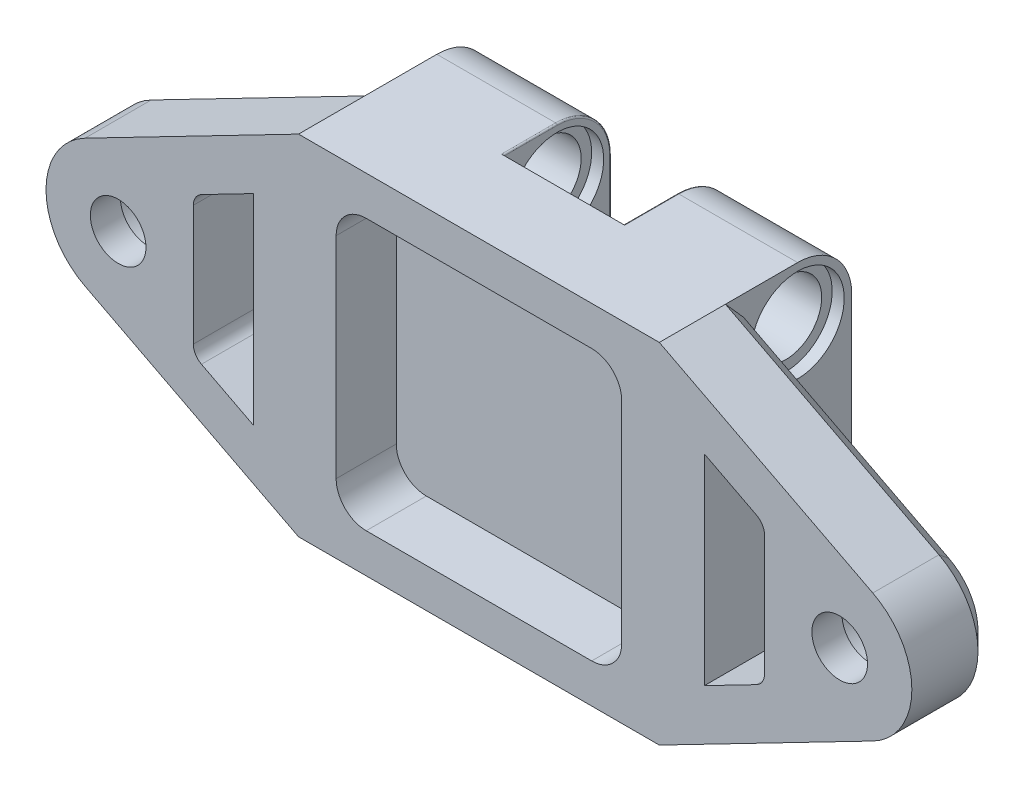
from build123d import *

# Parameters (mm, degrees)
SKETCH_2_R                 = 1.85
EXTRUDE_1_DEPTH            = 5.6
SKETCH_3_R                 = 2.95
CUT_EXTRUDE_1_DEPTH        = 3.6
SKETCH_4_W                 = 8
SKETCH_4_H                 = 23.2
EXTRUDE_2_DEPTH            = 7.2
SKETCH_5_R                 = 2.4
CUT_EXTRUDE_2_DEPTH        = 29.8
CUT_EXTRUDE_2_DEPTH_BACK   = 29.8
FILLET_1_R                 = 3.6
SKETCH_6_R                 = 3.1
CUT_EXTRUDE_3_DEPTH        = 0.8
MIRROR_2_COPY_1_SKETCH_R   = 3.1
MIRROR_2_COPY_1_DEPTH      = 0.8
CUT_EXTRUDE_4_DEPTH        = 6.6
SKETCH_8_W                 = 19
SKETCH_8_H                 = 18
CUT_EXTRUDE_5_DEPTH        = 4
FILLET_3_R                 = 2
FILLET_4_R                 = 0.1
FILLET_5_R                 = 1
CHAMFER_1_SIZE             = 1
FILLET_5_OF_MIRROR_3_R     = 1
CHAMFER_1_OF_MIRROR_3_SIZE = 1
CHAMFER_2_SIZE             = 1.2
SKETCH_9_W                 = 0.1
SKETCH_9_H                 = 1.6
EXTRUDE_3_DEPTH            = 8


with BuildPart() as part:
    # ｽｹｯﾁ2 → ﾎﾞｽ - 押し出し1 (new body)
    with BuildSketch(Plane.XY):
        with BuildLine():
            Line((-12, 11.6), (-26.202629265, 4.264788895))
            ThreePointArc((-26.202629265, 4.264788895), (-28.8, 0), (-26.202629265, -4.264788895))
            Line((-26.202629265, -4.264788895), (-12, -11.6))
            Line((-12, -11.6), (12, -11.6))
            Line((12, -11.6), (26.202629265, -4.264788895))
            ThreePointArc((26.202629265, -4.264788895), (28.8, 0), (26.202629265, 4.264788895))
            Line((26.202629265, 4.264788895), (12, 11.6))
            Line((12, 11.6), (-12, 11.6))
        make_face()
        with Locations((-24, 0)):
            Circle(SKETCH_2_R, mode=Mode.SUBTRACT)
        with Locations((24, 0)):
            Circle(SKETCH_2_R, mode=Mode.SUBTRACT)
    extrude(amount=EXTRUDE_1_DEPTH)

    # ｽｹｯﾁ3 → ｶｯﾄ - 押し出し1 (cut)
    with BuildSketch(Plane(origin=(0, 0, 0), x_dir=(-1, 0, 0), z_dir=(0, 0, -1))):
        with Locations((-24, 0)):
            Circle(SKETCH_3_R)
        with Locations((24, 0)):
            Circle(SKETCH_3_R)
    extrude(amount=-CUT_EXTRUDE_1_DEPTH, mode=Mode.SUBTRACT)

    # ｽｹｯﾁ4 → ﾎﾞｽ - 押し出し2 (add)
    with BuildSketch(Plane(origin=(0, 0, 0), x_dir=(-1, 0, 0), z_dir=(0, 0, -1))):
        with Locations((-8, 0)):
            Rectangle(SKETCH_4_W, SKETCH_4_H)
        with Locations((8, 0)):
            Rectangle(SKETCH_4_W, SKETCH_4_H)
    extrude(amount=EXTRUDE_2_DEPTH)

    # ｽｹｯﾁ5 → ｶｯﾄ - 押し出し2 (cut, two sides)
    with BuildSketch(Plane(origin=(0, 0, 0), x_dir=(0, 0, -1), z_dir=(1, 0, 0))) as cut_extrude_2_sk:
        with Locations((3.6, 8)):
            Circle(SKETCH_5_R)
        with Locations((3.6, -8)):
            Circle(SKETCH_5_R)
        with BuildLine():
            Line((2.8, 2.2627417), (2.8, 0.8))
            Line((2.8, 0.8), (1.3372583, 0.8))
            ThreePointArc((1.3372583, 0.8), (1.2, 0), (1.3372583, -0.8))
            Line((1.3372583, -0.8), (2.8, -0.8))
            Line((2.8, -0.8), (2.8, -2.2627417))
            ThreePointArc((2.8, -2.2627417), (3.6, -2.4), (4.4, -2.2627417))
            Line((4.4, -2.2627417), (4.4, -0.8))
            Line((4.4, -0.8), (5.8627417, -0.8))
            ThreePointArc((5.8627417, -0.8), (6, 0), (5.8627417, 0.8))
            Line((5.8627417, 0.8), (4.4, 0.8))
            Line((4.4, 0.8), (4.4, 2.2627417))
            ThreePointArc((4.4, 2.2627417), (3.6, 2.4), (2.8, 2.2627417))
        make_face()
    extrude(amount=CUT_EXTRUDE_2_DEPTH, mode=Mode.SUBTRACT)
    extrude(cut_extrude_2_sk.sketch, amount=-CUT_EXTRUDE_2_DEPTH_BACK, mode=Mode.SUBTRACT)

    # ﾌｨﾚｯﾄ1
    fillet_1_edges = [part.edges().sort_by_distance(p)[0] for p in [
        (8, -11.6, -7.2),
        (8, 11.6, -7.2),
        (-8, -11.6, -7.2),
        (-8, 11.6, -7.2),
    ]]
    fillet(fillet_1_edges, radius=FILLET_1_R)

    # ｽｹｯﾁ6 → ｶｯﾄ - 押し出し3 (cut)
    with BuildSketch(Plane.ZY.offset(-4)):
        with Locations((-3.6, 8)):
            Circle(SKETCH_6_R)
        with Locations((-3.6, -8)):
            Circle(SKETCH_6_R)
    cut_extrude_3 = extrude(amount=-CUT_EXTRUDE_3_DEPTH, mode=Mode.SUBTRACT)

    # ﾐﾗｰ1: ｶｯﾄ - 押し出し3 across plane
    add(cut_extrude_3.mirror(Plane(origin=(8, 0, 0), x_dir=(0, 0, 1), z_dir=(1, 0, 0))), mode=Mode.SUBTRACT)

    # ﾐﾗｰ2: ｶｯﾄ - 押し出し3 across plane
    add(cut_extrude_3.mirror(Plane(origin=(0, 0, 0), x_dir=(0, 0, 1), z_dir=(1, 0, 0))), mode=Mode.SUBTRACT)

    # ﾐﾗｰ2 copy 1 sketch → ﾐﾗｰ2 copy 1 (cut)
    with BuildSketch(Plane.ZY.offset(12)):
        with Locations((-3.6, 8)):
            Circle(MIRROR_2_COPY_1_SKETCH_R)
        with Locations((-3.6, -8)):
            Circle(MIRROR_2_COPY_1_SKETCH_R)
    extrude(amount=-MIRROR_2_COPY_1_DEPTH, mode=Mode.SUBTRACT)

    # ｽｹｯﾁ7 → ｶｯﾄ - 押し出し4 (cut, through all)
    with BuildSketch(Plane(origin=(0, 0, 0), x_dir=(-1, 0, 0), z_dir=(0, 0, -1))):
        Polygon((-19, 4.608234267), (-19, -4.608234267), (-15, -6.6741084), (-15, 6.6741084), align=None)
    cut_extrude_4 = extrude(amount=-CUT_EXTRUDE_4_DEPTH, mode=Mode.SUBTRACT)

    # ｽｹｯﾁ8 → ｶｯﾄ - 押し出し5 (cut)
    with BuildSketch(Plane.XY.offset(5.6)):
        Rectangle(SKETCH_8_W, SKETCH_8_H)
    extrude(amount=-CUT_EXTRUDE_5_DEPTH, mode=Mode.SUBTRACT)

    # ﾌｨﾚｯﾄ3
    fillet_3_edges = [part.edges().sort_by_distance(p)[0] for p in [
        (-9.5, -9, 3.6),
        (-9.5, 9, 3.6),
        (9.5, 9, 3.6),
        (9.5, -9, 3.6),
    ]]
    fillet(fillet_3_edges, radius=FILLET_3_R)

    # ﾌｨﾚｯﾄ4
    fillet_4_edges = [part.edges().sort_by_distance(p)[0] for p in [
        (4, 0, -7.2),
        (4, 11.6, -1.8),
        (4, -11.6, -1.8),
        (4, 10.545584412, -6.145584412),
        (4, -10.545584412, -6.145584412),
        (-4, -11.6, -1.8),
        (-4, 0, -7.2),
        (-4, 11.6, -1.8),
        (-4, 10.545584412, -6.145584412),
        (-4, -10.545584412, -6.145584412),
    ]]
    fillet(fillet_4_edges, radius=FILLET_4_R)

    # ﾌｨﾚｯﾄ5
    fillet_5_edges = [part.edges().sort_by_distance(p)[0] for p in [
        (19, 4.608234267, 2.8),
        (19, -4.608234267, 2.8),
    ]]
    fillet(fillet_5_edges, radius=FILLET_5_R)

    # 面取り1
    chamfer_1_edges = [part.edges().sort_by_distance(p)[0] for p in [
        (16.729440548, 5.780906776, 0),
        (15, 0, 0),
        (16.729440548, -5.780906776, 0),
        (19, 0, 0),
        (18.854072918, -4.519360763, 0),
        (18.854072918, 4.519360763, 0),
    ]]
    chamfer(chamfer_1_edges, length=CHAMFER_1_SIZE)

    # ﾐﾗｰ3: ｶｯﾄ - 押し出し4 across plane
    add(cut_extrude_4.mirror(Plane(origin=(0, 0, 0), x_dir=(0, 0, 1), z_dir=(1, 0, 0))), mode=Mode.SUBTRACT)

    # ﾌｨﾚｯﾄ5 of ﾐﾗｰ3
    fillet_5_of_mirror_3_edges = [part.edges().sort_by_distance(p)[0] for p in [
        (-19, 4.608234267, 2.8),
        (-19, -4.608234267, 2.8),
    ]]
    fillet(fillet_5_of_mirror_3_edges, radius=FILLET_5_OF_MIRROR_3_R)

    # 面取り1 of ﾐﾗｰ3
    chamfer_1_of_mirror_3_edges = [part.edges().sort_by_distance(p)[0] for p in [
        (-16.729440548, 5.780906776, 0),
        (-15, 0, 0),
        (-16.729440548, -5.780906776, 0),
        (-19, 0, 0),
        (-18.854072918, -4.519360763, 0),
        (-18.854072918, 4.519360763, 0),
    ]]
    chamfer(chamfer_1_of_mirror_3_edges, length=CHAMFER_1_OF_MIRROR_3_SIZE)

    # 面取り2
    chamfer_2_edges = [part.edges().sort_by_distance(p)[0] for p in [
        (-19.101314633, -7.932394448, 0),
        (-28.8, 0, 0),
        (-19.101314633, 7.932394448, 0),
        (19.101314633, 7.932394448, 0),
        (28.8, 0, 0),
        (19.101314633, -7.932394448, 0),
    ]]
    chamfer(chamfer_2_edges, length=CHAMFER_2_SIZE)

    # ｽｹｯﾁ9 → ﾎﾞｽ - 押し出し3 (add)
    with BuildSketch(Plane(origin=(12, 0, 0), x_dir=(0, 0, -1), z_dir=(1, 0, 0))):
        with Locations((4.45, 0)):
            Rectangle(SKETCH_9_W, SKETCH_9_H)
    extrude_3 = extrude(amount=-EXTRUDE_3_DEPTH)

    # ﾐﾗｰ4: ﾎﾞｽ - 押し出し3 across plane
    add(extrude_3.mirror(Plane(origin=(0, 0, 0), x_dir=(0, 0, 1), z_dir=(1, 0, 0))))


solid = part.part
